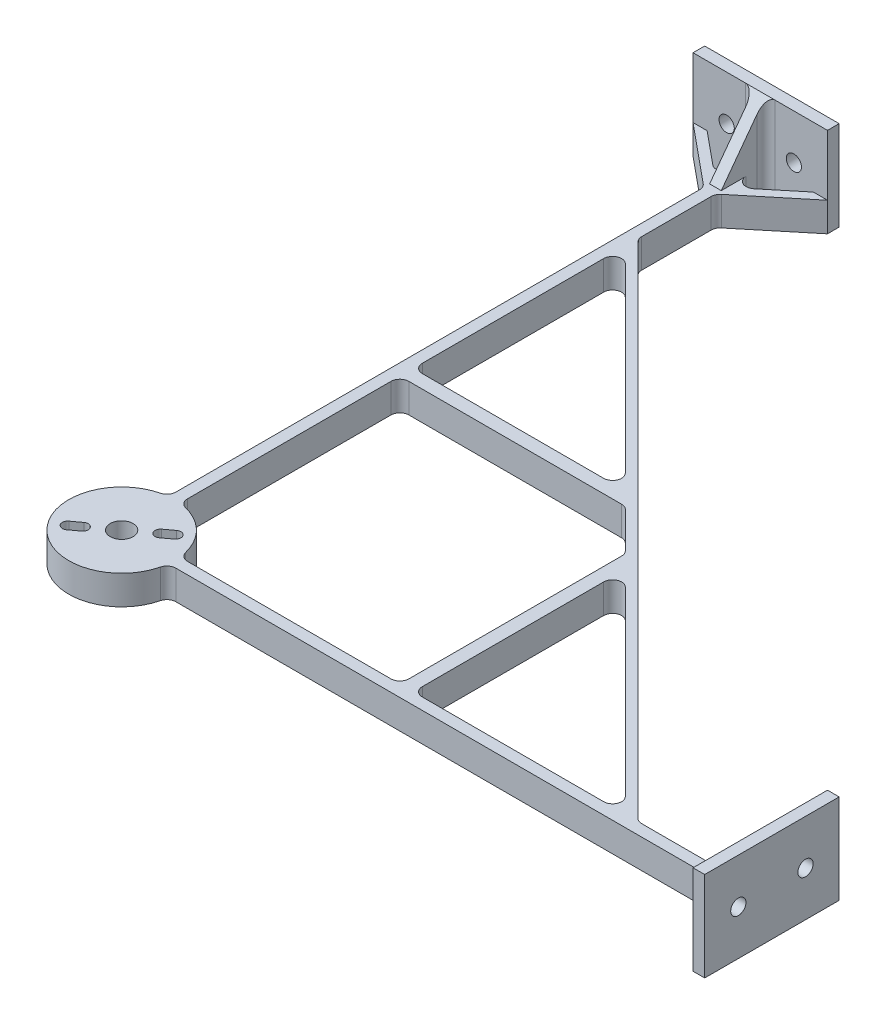
from build123d import *

# Parameters (mm, degrees)
SKETCH1_R           = 3.2385
BOSS_EXTRUDE1_DEPTH = 8.255
SKETCH3_W           = 3.302
SKETCH3_H           = 38.1
SKETCH3_W_2         = 38.1
SKETCH3_H_2         = 3.302
BOSS_EXTRUDE3_DEPTH = 25.4
SKETCH5_R           = 2.159
CUT_EXTRUDE1_DEPTH  = 204.327
SKETCH6_W           = 12.7
SKETCH6_H           = 3.302
BOSS_EXTRUDE5_DEPTH = 25.4
CUT_EXTRUDE2_DEPTH  = 25.4
SKETCH8_W           = 3.302
SKETCH8_H           = 12.7
BOSS_EXTRUDE6_DEPTH = 25.4
CUT_EXTRUDE3_DEPTH  = 25.4
FILLET1_R           = 2.54


with BuildPart() as part:
    # Sketch1 → Boss-Extrude1 (new body)
    with BuildSketch(Plane(origin=(0, 0, 0), x_dir=(1, 0, 0), z_dir=(0, 1, 0))):
        with BuildLine():
            Line((-1.651, 166.628963684), (-1.651, 14.89477744))
            ThreePointArc((-1.651, 14.89477744), (-10.596702223, -10.596702223), (14.89477744, -1.651))
            Line((14.89477744, -1.651), (166.628963684, -1.651))
            Line((166.628963684, -1.651), (180.975, -19.05))
            Line((180.975, -19.05), (180.975, -15.057345133))
            Line((180.975, -15.057345133), (169.921036316, -1.651))
            Line((169.921036316, -1.651), (180.975, -1.651))
            Line((180.975, -1.651), (180.975, 1.651))
            Line((180.975, 1.651), (169.921036316, 1.651))
            Line((169.921036316, 1.651), (180.975, 15.057345133))
            Line((180.975, 15.057345133), (180.975, 19.05))
            Line((180.975, 19.05), (166.628963684, 1.651))
            Line((166.628963684, 1.651), (144.671051224, 1.651))
            Line((144.671051224, 1.651), (1.651, 144.671051224))
            Line((1.651, 144.671051224), (1.651, 166.628963684))
            Line((1.651, 166.628963684), (19.05, 180.975))
            Line((19.05, 180.975), (15.057345133, 180.975))
            Line((15.057345133, 180.975), (1.651, 169.921036316))
            Line((1.651, 169.921036316), (1.651, 180.975))
            Line((1.651, 180.975), (-1.651, 180.975))
            Line((-1.651, 180.975), (-1.651, 169.921036316))
            Line((-1.651, 169.921036316), (-15.057345133, 180.975))
            Line((-15.057345133, 180.975), (-19.05, 180.975))
            Line((-19.05, 180.975), (-1.651, 166.628963684))
        make_face()
        with BuildLine():
            Line((-9.686234559, -5.271576621), (-7.236078848, -3.458556767))
            ThreePointArc((-7.236078848, -3.458556767), (-5.104491065, -3.777124696), (-5.423058993, -5.908712478))
            Line((-5.423058993, -5.908712478), (-7.873214705, -7.721732332))
            ThreePointArc((-7.873214705, -7.721732332), (-10.004802487, -7.403164404), (-9.686234559, -5.271576621))
        make_face(mode=Mode.SUBTRACT)
        Circle(SKETCH1_R, mode=Mode.SUBTRACT)
        with BuildLine():
            ThreePointArc((7.236078848, 3.458556767), (5.104491065, 3.777124696), (5.423058993, 5.908712478))
            Line((5.423058993, 5.908712478), (7.873214705, 7.721732332))
            ThreePointArc((7.873214705, 7.721732332), (10.004802487, 7.403164404), (9.686234559, 5.271576621))
            Line((9.686234559, 5.271576621), (7.236078848, 3.458556767))
        make_face(mode=Mode.SUBTRACT)
        with BuildLine():
            Line((77.202140867, 1.651), (14.89477744, 1.651))
            ThreePointArc((14.89477744, 1.651), (10.596702223, 10.596702223), (1.651, 14.89477744))
            Line((1.651, 14.89477744), (1.651, 77.202140867))
            Line((1.651, 77.202140867), (65.527807909, 77.202140867))
            Line((65.527807909, 77.202140867), (77.202140867, 65.527807909))
            Line((77.202140867, 65.527807909), (77.202140867, 1.651))
        make_face(mode=Mode.SUBTRACT)
        Polygon((141.078948776, 1.651), (81.012140867, 1.651), (81.012140867, 61.717807909), align=None, mode=Mode.SUBTRACT)
        Polygon((1.651, 81.012140867), (1.651, 141.078948776), (61.717807909, 81.012140867), align=None, mode=Mode.SUBTRACT)
    extrude(amount=BOSS_EXTRUDE1_DEPTH)

    # Sketch3 → Boss-Extrude3 (add)
    with BuildSketch(Plane(origin=(0, 0, 0), x_dir=(1, 0, 0), z_dir=(0, 1, 0))):
        with Locations((182.626, 0)):
            Rectangle(SKETCH3_W, SKETCH3_H)
        with Locations((0, 182.626)):
            Rectangle(SKETCH3_W_2, SKETCH3_H_2)
    extrude(amount=BOSS_EXTRUDE3_DEPTH)

    # Sketch5 → Cut-Extrude1 (cut, through all)
    with BuildSketch(Plane(origin=(184.277, 0, 0), x_dir=(0, 0, -1), z_dir=(1, 0, 0))):
        with Locations((-9.525, 12.7)):
            Circle(SKETCH5_R)
        with Locations((9.525, 12.7)):
            Circle(SKETCH5_R)
    cut_extrude1 = extrude(amount=-CUT_EXTRUDE1_DEPTH, mode=Mode.SUBTRACT)

    # Mirror1: Cut-Extrude1 across plane
    add(cut_extrude1.mirror(Plane(origin=(0, 0, 0), x_dir=(-0.707106781, 0, 0.707106781), z_dir=(0.707106781, 0, 0.707106781))), mode=Mode.SUBTRACT)

    # Sketch6 → Boss-Extrude5 (add)
    with BuildSketch(Plane(origin=(0, 0, 0), x_dir=(1, 0, 0), z_dir=(0, 1, 0))):
        with Locations((174.625, 0)):
            Rectangle(SKETCH6_W, SKETCH6_H)
    extrude(amount=BOSS_EXTRUDE5_DEPTH)

    # Sketch7 → Cut-Extrude2 (cut)
    with BuildSketch(Plane(origin=(0, 0, -1.651), x_dir=(-1, 0, 0), z_dir=(0, 0, -1))):
        Polygon((-180.975, 25.4), (-168.275, 8.255), (-168.275, 25.4), align=None)
    extrude(amount=-CUT_EXTRUDE2_DEPTH, mode=Mode.SUBTRACT)

    # Sketch8 → Boss-Extrude6 (add)
    with BuildSketch(Plane(origin=(0, 0, 0), x_dir=(1, 0, 0), z_dir=(0, 1, 0))):
        with Locations((0, 174.625)):
            Rectangle(SKETCH8_W, SKETCH8_H)
    extrude(amount=BOSS_EXTRUDE6_DEPTH)

    # Sketch9 → Cut-Extrude3 (cut)
    with BuildSketch(Plane(origin=(1.651, 0, 0), x_dir=(0, 0, -1), z_dir=(1, 0, 0))):
        Polygon((180.975, 25.4), (168.275, 8.255), (168.275, 25.4), align=None)
    extrude(amount=-CUT_EXTRUDE3_DEPTH, mode=Mode.SUBTRACT)

    # Fillet1
    fillet1_edges = [part.edges().sort_by_distance(p)[0] for p in [
        (-1.651, 4.1275, -166.628963684),
        (-1.651, 4.1275, -169.921036316),
        (-1.651, 12.7, -180.975),
        (1.651, 12.7, -180.975),
        (1.651, 4.1275, -169.921036316),
        (1.651, 4.1275, -166.628963684),
        (1.651, 4.1275, -144.671051224),
        (144.671051224, 4.1275, -1.651),
        (166.628963684, 4.1275, -1.651),
        (169.921036316, 4.1275, -1.651),
        (180.975, 12.7, -1.651),
        (180.975, 12.7, 1.651),
        (169.921036316, 4.1275, 1.651),
        (166.628963684, 4.1275, 1.651),
        (14.89477744, 4.1275, 1.651),
        (-1.651, 4.1275, -14.89477744),
        (61.717807909, 4.1275, -81.012140867),
        (1.651, 4.1275, -141.078948776),
        (1.651, 4.1275, -81.012140867),
        (77.202140867, 4.1275, -1.651),
        (77.202140867, 4.1275, -65.527807909),
        (65.527807909, 4.1275, -77.202140867),
        (1.651, 4.1275, -77.202140867),
        (1.651, 4.1275, -14.89477744),
        (14.89477744, 4.1275, -1.651),
        (141.078948776, 4.1275, -1.651),
        (81.012140867, 4.1275, -61.717807909),
        (81.012140867, 4.1275, -1.651),
    ]]
    fillet(fillet1_edges, radius=FILLET1_R)


solid = part.part
